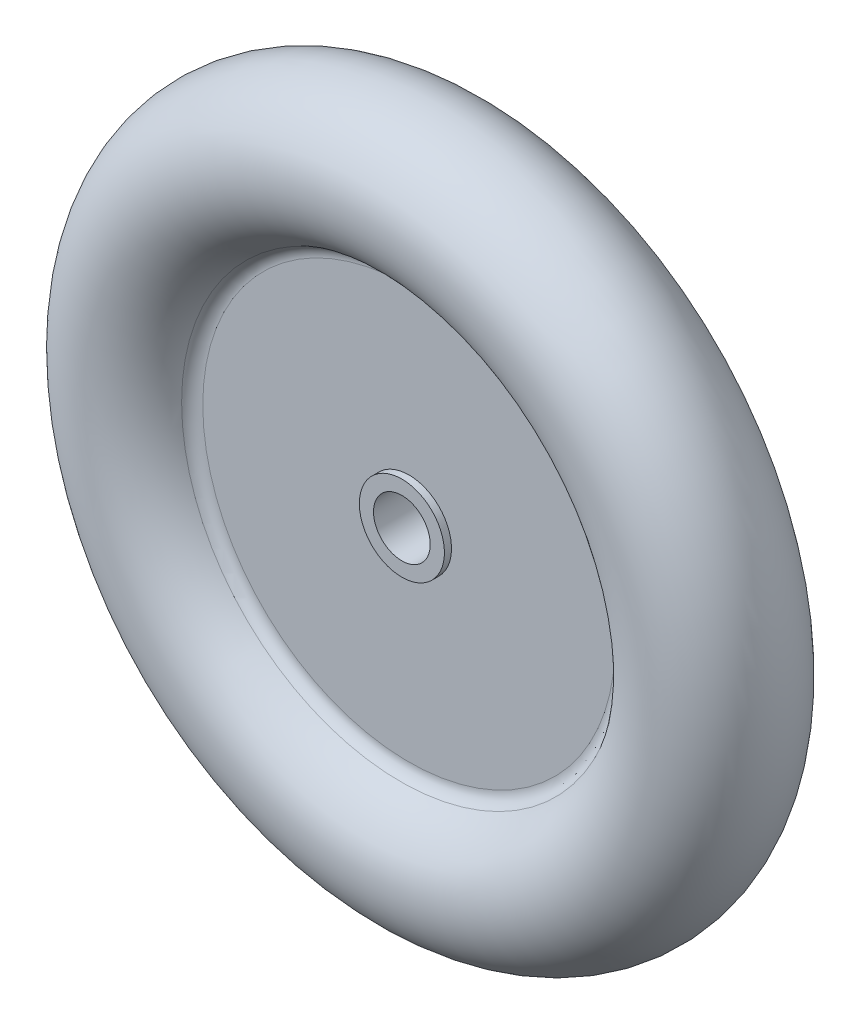
from build123d import *


with BuildPart() as part:
    # Sketch1 → Revolve1 (revolve)
    with BuildSketch(Plane(origin=(0, 0, 0), x_dir=(0, 0, -1), z_dir=(1, 0, 0)), mode=Mode.PRIVATE) as revolve1_sk:
        with BuildLine():
            Line((-1.5, 3), (-2, 3))
            Line((-2, 3), (-2, 2))
            Line((-2, 2), (2, 2))
            Line((2, 2), (2, 3))
            Line((2, 3), (1.5, 3))
            Line((1.5, 3), (1.5, 14.545643943))
            ThreePointArc((1.5, 14.545643943), (1.658374588, 15.085705668), (2.083333333, 15.454703286))
            ThreePointArc((2.083333333, 15.454703286), (0, 25), (-2.083333333, 15.454703286))
            ThreePointArc((-2.083333333, 15.454703286), (-1.658374588, 15.085705668), (-1.5, 14.545643943))
            Line((-1.5, 14.545643943), (-1.5, 3))
        make_face()
    revolve(revolve1_sk.sketch.rotate(Axis((0, 0, -18.162203791), (0, 0, 1)), 90), axis=Axis((0, 0, -18.162203791), (0, 0, 1)))  # turned: the seam where the file's is


solid = part.part
